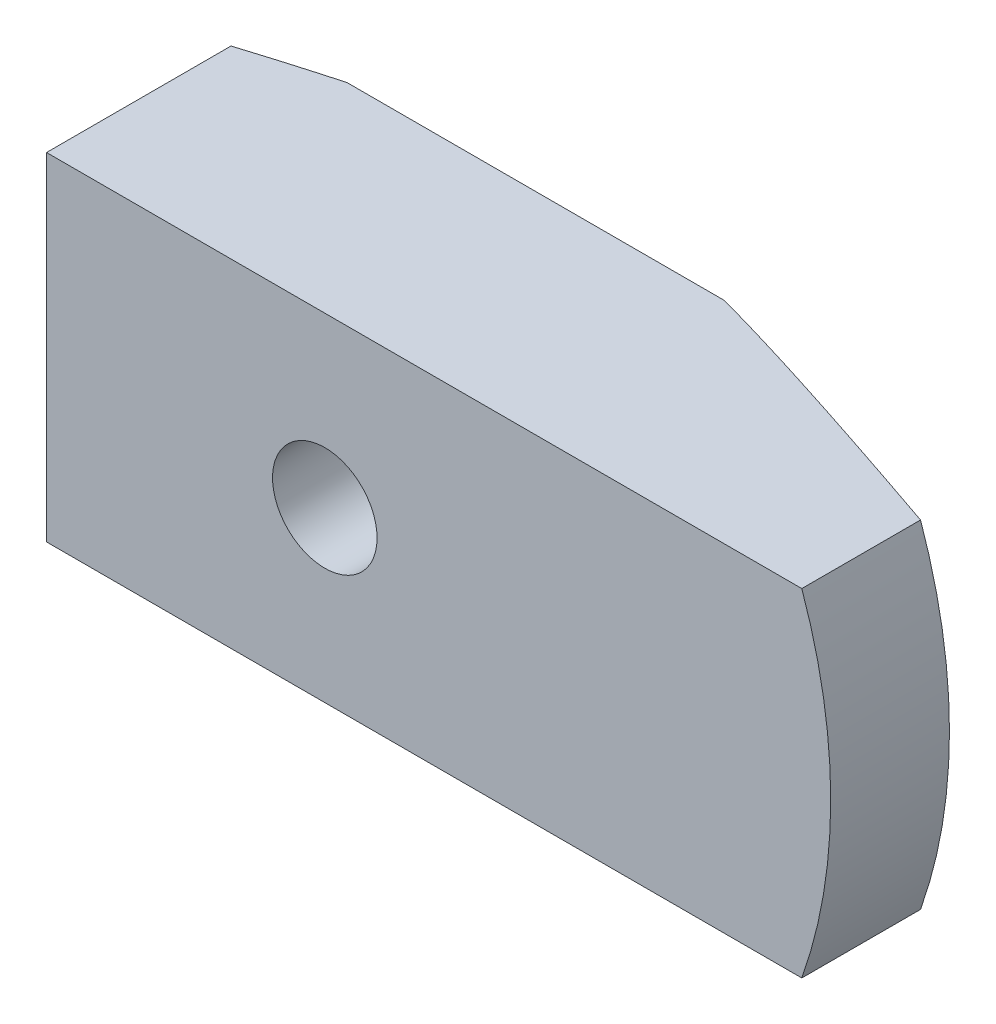
from build123d import *

# Parameters (mm, degrees)
SKETCH1_R           = 38.1
BOSS_EXTRUDE1_DEPTH = 15.875
SKETCH2_R           = 3.937
CUT_EXTRUDE1_DEPTH  = 5.715
SKETCH3_R           = 2.450575626
CUT_EXTRUDE2_DEPTH  = 55.831064188
CHAMFER1_SIZE       = 19.05
CHAMFER1_SIZE2      = 6.933632963
CUT_EXTRUDE3_DEPTH  = 57.171484091


with BuildPart() as part:
    # Sketch1 → Boss-Extrude1 (new body)
    with BuildSketch(Plane.XY):
        Circle(SKETCH1_R)
    extrude(amount=BOSS_EXTRUDE1_DEPTH)

    # Sketch2 → Cut-Extrude1 (cut)
    with BuildSketch(Plane.XY.offset(15.875)):
        Circle(SKETCH2_R)
    extrude(amount=-CUT_EXTRUDE1_DEPTH, mode=Mode.SUBTRACT)

    # Sketch3 → Cut-Extrude2 (cut, through all)
    with BuildSketch(Plane.XY.offset(10.16)):
        Circle(SKETCH3_R)
    extrude(amount=-CUT_EXTRUDE2_DEPTH, mode=Mode.SUBTRACT)

    # Chamfer1
    chamfer1_edges = [part.edges().sort_by_distance(p)[0] for p in [
        (-38.1, 0, 0),
    ]]
    chamfer1_side = [part.faces().sort_by_distance(p)[0] for p in [
        (-37.022369265, 0, 0),
    ]]
    chamfer(chamfer1_edges, length=CHAMFER1_SIZE, length2=CHAMFER1_SIZE2, reference=chamfer1_side[0])

    # Sketch4 → Cut-Extrude3 (cut, through all)
    with BuildSketch(Plane.XY.offset(15.875)):
        with BuildLine():
            ThreePointArc((35.921024484, 12.7), (-38.1, 0), (35.921024484, -12.7))
            Line((35.921024484, -12.7), (-20.955, -12.7))
            Line((-20.955, -12.7), (-20.955, 12.7))
            Line((-20.955, 12.7), (35.921024484, 12.7))
        make_face()
    extrude(amount=-CUT_EXTRUDE3_DEPTH, mode=Mode.SUBTRACT)


solid = part.part
